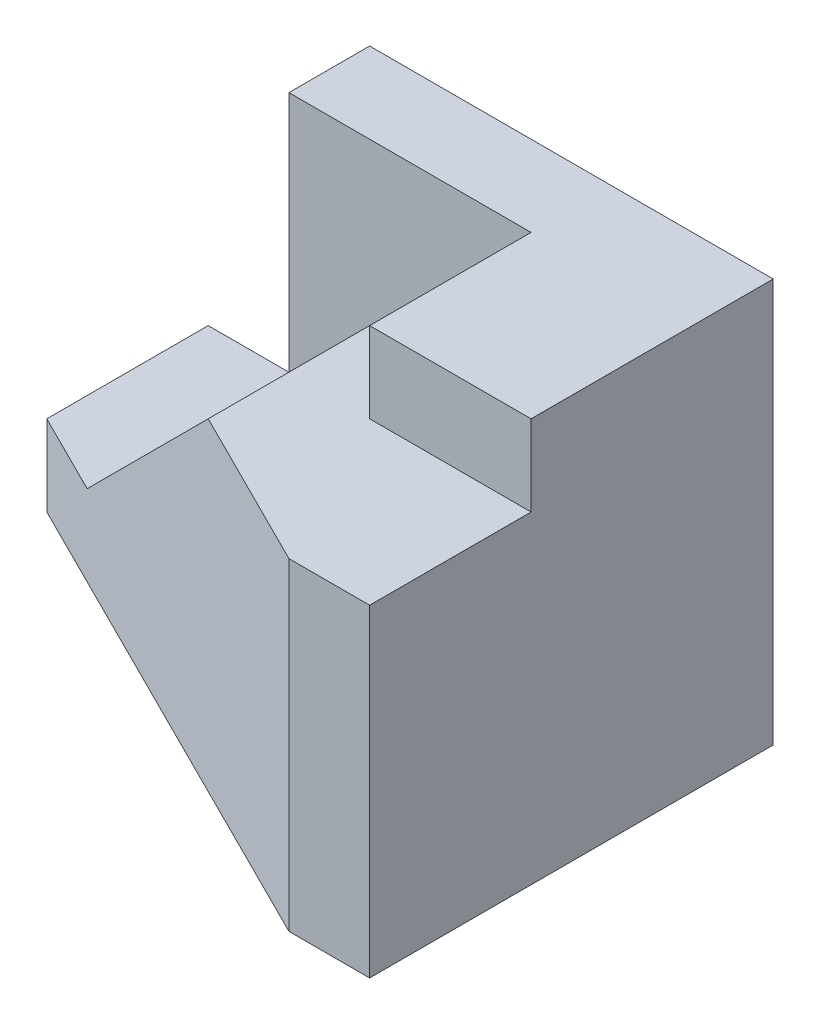
from build123d import *

# Parameters (mm, degrees)
SKETCH1_W           = 70
SKETCH1_H           = 50
BOSS_EXTRUDE1_DEPTH = 50
CUT_EXTRUDE1_DEPTH  = 50
CUT_EXTRUDE2_DEPTH  = 50
CUT_EXTRUDE3_DEPTH  = 10
CUT_EXTRUDE4_DEPTH  = 57


with BuildPart() as part:
    # Sketch1 → Boss-Extrude1 (new body)
    with BuildSketch(Plane.XY):
        with Locations((35, 25)):
            Rectangle(SKETCH1_W, SKETCH1_H)
    extrude(amount=BOSS_EXTRUDE1_DEPTH)

    # Sketch2 → Cut-Extrude1 (cut)
    with BuildSketch(Plane.XY.offset(50)):
        Polygon((0, 10), (10, 10), (20, 20), (20, 50), (0, 50), align=None)
    extrude(amount=-CUT_EXTRUDE1_DEPTH, mode=Mode.SUBTRACT)

    # Sketch3 → Cut-Extrude2 (cut)
    with BuildSketch(Plane.XZ):
        Polygon((0, 20), (60, 50), (0, 50), align=None)
    extrude(amount=-CUT_EXTRUDE2_DEPTH, mode=Mode.SUBTRACT)

    # Sketch4 → Cut-Extrude3 (cut)
    with BuildSketch(Plane(origin=(0, 50, 0), x_dir=(1, 0, 0), z_dir=(0, 1, 0))):
        Polygon((20, -10), (50, -10), (50, -30), (70, -30), (70, -50), (60, -50), (20, -30), align=None)
    extrude(amount=-CUT_EXTRUDE3_DEPTH, mode=Mode.SUBTRACT)

    # Sketch5 → Cut-Extrude4 (cut)
    with BuildSketch(Plane.XY.offset(10)):
        Polygon((20, 20), (40, 40), (20, 40), align=None)
    extrude(amount=CUT_EXTRUDE4_DEPTH, mode=Mode.SUBTRACT)


solid = part.part
